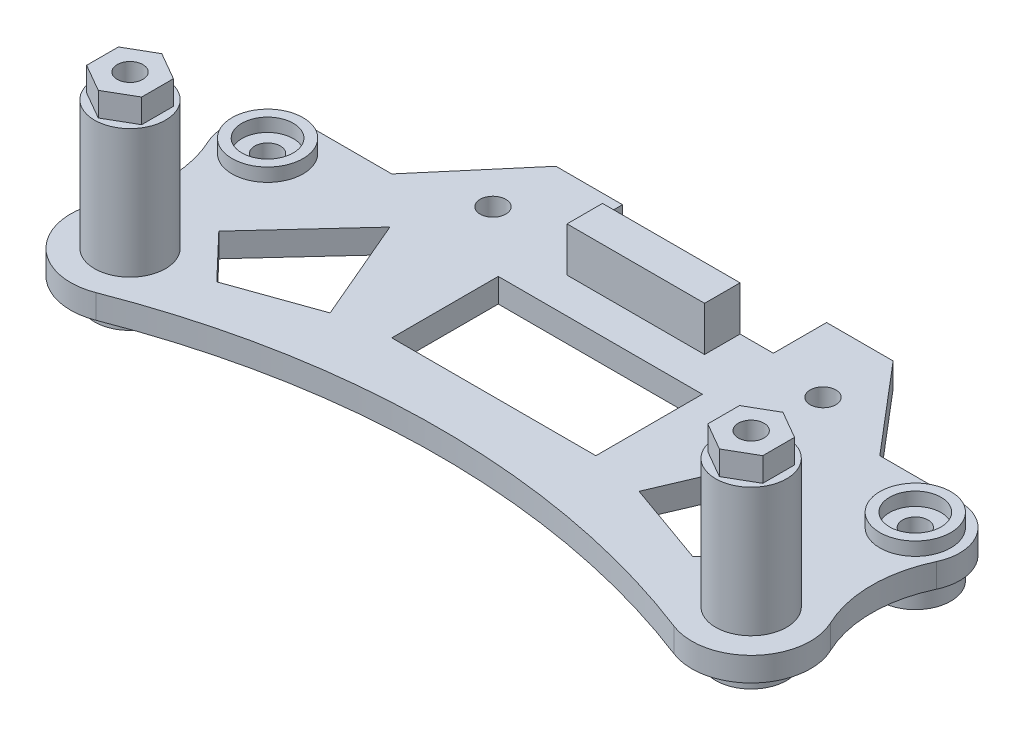
from build123d import *

# Parameters (mm, degrees)
SKETCH1_R             = 4
SKETCH1_R_2           = 2.1
BOSS_EXTRUDE1_DEPTH   = 2.5
BOSS_EXTRUDE1_2_DEPTH = 2.5
BOSS_EXTRUDE1_3_DEPTH = 2.5
BOSS_EXTRUDE1_4_DEPTH = 2.5
SKETCH1_R_3           = 4.3
SKETCH1_R_4           = 2.9
BOSS_EXTRUDE1_5_DEPTH = 2.5
BOSS_EXTRUDE1_6_DEPTH = 2.5
SKETCH2_R             = 1.45
SKETCH2_R_2           = 2.25
SKETCH2_W             = 23
SKETCH2_H             = 12
BOSS_EXTRUDE2_DEPTH   = 2.7
SKETCH3_W             = 15.5
SKETCH3_H             = 4
BOSS_EXTRUDE3_DEPTH   = 5
SKETCH4_R             = 4
SKETCH4_R_2           = 2.9
BOSS_EXTRUDE4_DEPTH   = 1.5
SKETCH5_R             = 4
SKETCH5_R_2           = 2.1
BOSS_EXTRUDE5_DEPTH   = 14.5
SKETCH6_R             = 1.45
BOSS_EXTRUDE6_DEPTH   = 2.7


with BuildPart() as part:
    # Sketch1 → Boss-Extrude1 (new body)
    with BuildSketch(Plane(origin=(0, 0, 0), x_dir=(1, 0, 0), z_dir=(0, 1, 0))):
        with Locations((-35, 0)):
            Circle(SKETCH1_R)
        with Locations((-35, 0)):
            Circle(SKETCH1_R_2, mode=Mode.SUBTRACT)
    extrude(amount=-BOSS_EXTRUDE1_DEPTH)


with BuildPart() as body_2:
    # Sketch1 → Boss-Extrude1 2 (new body)
    with BuildSketch(Plane(origin=(0, 0, 0), x_dir=(1, 0, 0), z_dir=(0, 1, 0))):
        with Locations((35, 0)):
            Circle(SKETCH1_R)
        with Locations((35, 0)):
            Circle(SKETCH1_R_2, mode=Mode.SUBTRACT)
    extrude(amount=-BOSS_EXTRUDE1_2_DEPTH)


with BuildPart() as body_3:
    # Sketch1 → Boss-Extrude1 3 (new body)
    with BuildSketch(Plane(origin=(0, 0, 0), x_dir=(1, 0, 0), z_dir=(0, 1, 0))):
        with Locations((-36.5, 17)):
            Circle(SKETCH1_R)
        Polygon((-39.5, 15.267949192), (-36.5, 13.535898385), (-33.5, 15.267949192), (-33.5, 18.732050808), (-36.5, 20.464101615), (-39.5, 18.732050808), align=None, mode=Mode.SUBTRACT)
    extrude(amount=-BOSS_EXTRUDE1_3_DEPTH)



with BuildPart() as body_4:
    # Sketch1 → Boss-Extrude1 4 (new body)
    with BuildSketch(Plane(origin=(0, 0, 0), x_dir=(1, 0, 0), z_dir=(0, 1, 0))):
        with Locations((36.5, 17)):
            Circle(SKETCH1_R)
        Polygon((36.5, 20.464101615), (33.5, 18.732050808), (33.5, 15.267949192), (36.5, 13.535898385), (39.5, 15.267949192), (39.5, 18.732050808), align=None, mode=Mode.SUBTRACT)
    extrude(amount=-BOSS_EXTRUDE1_4_DEPTH)


with BuildPart() as body_5:
    # Sketch1 → Boss-Extrude1 5 (new body)
    with BuildSketch(Plane(origin=(0, 0, 0), x_dir=(1, 0, 0), z_dir=(0, 1, 0))):
        with Locations((-18.6, 24.5)):
            Circle(SKETCH1_R_3)
        with Locations((-18.6, 24.5)):
            Circle(SKETCH1_R_4, mode=Mode.SUBTRACT)
    extrude(amount=-BOSS_EXTRUDE1_5_DEPTH)


with BuildPart() as body_6:
    # Sketch1 → Boss-Extrude1 6 (new body)
    with BuildSketch(Plane(origin=(0, 0, 0), x_dir=(1, 0, 0), z_dir=(0, 1, 0))):
        with Locations((18.6, 24.5)):
            Circle(SKETCH1_R_3)
        with Locations((18.6, 24.5)):
            Circle(SKETCH1_R_4, mode=Mode.SUBTRACT)
    extrude(amount=-BOSS_EXTRUDE1_6_DEPTH)


with BuildPart() as body_3_1:
    add(body_3.part)

    add(body_4.part)  # Boss-Extrude2 merges body 4
    # Sketch2 → Boss-Extrude2 (add)
    with BuildSketch(Plane(origin=(0, 0, 0), x_dir=(1, 0, 0), z_dir=(0, 1, 0))):
        with BuildLine():
            Line((-36.5, 22), (-27.5, 22))
            Line((-27.5, 22), (-19, 32))
            Line((-19, 32), (-11.5, 32))
            Line((-11.5, 32), (-11.5, 26))
            Line((-11.5, 26), (11.5, 26))
            Line((11.5, 26), (11.5, 32))
            Line((11.5, 32), (19, 32))
            Line((19, 32), (27.5, 22))
            Line((27.5, 22), (36.5, 22))
            ThreePointArc((36.5, 22), (40.722259459, 19.678157027), (41.023149536, 14.869010025))
            ThreePointArc((41.023149536, 14.869010025), (39.688000194, 8.872325293), (41.048762666, 2.881400737))
            ThreePointArc((41.048762666, 2.881400737), (39.910095198, -4.558614388), (32.574974147, -6.245738516))
            ThreePointArc((32.574974147, -6.245738516), (0, -0.143718583), (-32.574974147, -6.245738516))
            ThreePointArc((-32.574974147, -6.245738516), (-39.910095198, -4.558614388), (-41.048762666, 2.881400737))
            ThreePointArc((-41.048762666, 2.881400737), (-39.688000194, 8.872325293), (-41.023149536, 14.869010025))
            ThreePointArc((-41.023149536, 14.869010025), (-40.722259459, 19.678157027), (-36.5, 22))
        make_face()
        with Locations((-36.5, 17)):
            Circle(SKETCH2_R, mode=Mode.SUBTRACT)
        with Locations((-35, 0)):
            Circle(SKETCH2_R_2, mode=Mode.SUBTRACT)
        with Locations((35, 0)):
            Circle(SKETCH2_R_2, mode=Mode.SUBTRACT)
        with Locations((36.5, 17)):
            Circle(SKETCH2_R, mode=Mode.SUBTRACT)
        with Locations((18.6, 24.5)):
            Circle(SKETCH2_R, mode=Mode.SUBTRACT)
        with Locations((-18.6, 24.5)):
            Circle(SKETCH2_R, mode=Mode.SUBTRACT)
        Polygon((-17.408864349, 4.958212065), (-22.424277018, 16.711523526), (-31.664233186, 6.669313642), (-26.830375632, 1.606328243), align=None, mode=Mode.SUBTRACT)
        with Locations((0, 12)):
            Rectangle(SKETCH2_W, SKETCH2_H, mode=Mode.SUBTRACT)
        Polygon((31.664233186, 6.669313642), (26.830375632, 1.606328243), (17.408864349, 4.958212065), (22.424277018, 16.711523526), align=None, mode=Mode.SUBTRACT)
    extrude(amount=BOSS_EXTRUDE2_DEPTH)

    # Sketch3 → Boss-Extrude3 (add)
    with BuildSketch(Plane(origin=(0, 2.7, 0), x_dir=(1, 0, 0), z_dir=(0, 1, 0))):
        with Locations((0, 24)):
            Rectangle(SKETCH3_W, SKETCH3_H)
    extrude(amount=BOSS_EXTRUDE3_DEPTH)

    # Sketch4 → Boss-Extrude4 (add)
    with BuildSketch(Plane(origin=(0, 2.7, 0), x_dir=(1, 0, 0), z_dir=(0, 1, 0))):
        with Locations((-36.5, 17)):
            Circle(SKETCH4_R)
        with Locations((-36.5, 17)):
            Circle(SKETCH4_R_2, mode=Mode.SUBTRACT)
        with Locations((36.5, 17)):
            Circle(SKETCH4_R)
        with Locations((36.5, 17)):
            Circle(SKETCH4_R_2, mode=Mode.SUBTRACT)
    extrude(amount=BOSS_EXTRUDE4_DEPTH)

    # Sketch5 → Boss-Extrude5 (add)
    with BuildSketch(Plane(origin=(0, 2.7, 0), x_dir=(1, 0, 0), z_dir=(0, 1, 0))):
        with Locations((-35, 0)):
            Circle(SKETCH5_R)
        with Locations((-35, 0)):
            Circle(SKETCH5_R_2, mode=Mode.SUBTRACT)
        with Locations((35, 0)):
            Circle(SKETCH5_R)
        with Locations((35, 0)):
            Circle(SKETCH5_R_2, mode=Mode.SUBTRACT)
    extrude(amount=BOSS_EXTRUDE5_DEPTH)

    # Sketch6 → Boss-Extrude6 (add)
    with BuildSketch(Plane(origin=(0, 17.2, 0), x_dir=(1, 0, 0), z_dir=(0, 1, 0))):
        Polygon((-35, 3.579571669), (-38.1, 1.789785834), (-38.1, -1.789785834), (-35, -3.579571669), (-31.9, -1.789785834), (-31.9, 1.789785834), align=None)
        with Locations((-35, 0)):
            Circle(SKETCH6_R, mode=Mode.SUBTRACT)
        Polygon((31.9, 1.789785834), (31.9, -1.789785834), (35, -3.579571669), (38.1, -1.789785834), (38.1, 1.789785834), (35, 3.579571669), align=None)
        with Locations((35, 0)):
            Circle(SKETCH6_R, mode=Mode.SUBTRACT)
    extrude(amount=BOSS_EXTRUDE6_DEPTH)


solid = Compound([part.part, body_2.part, body_5.part, body_6.part, body_3_1.part])
